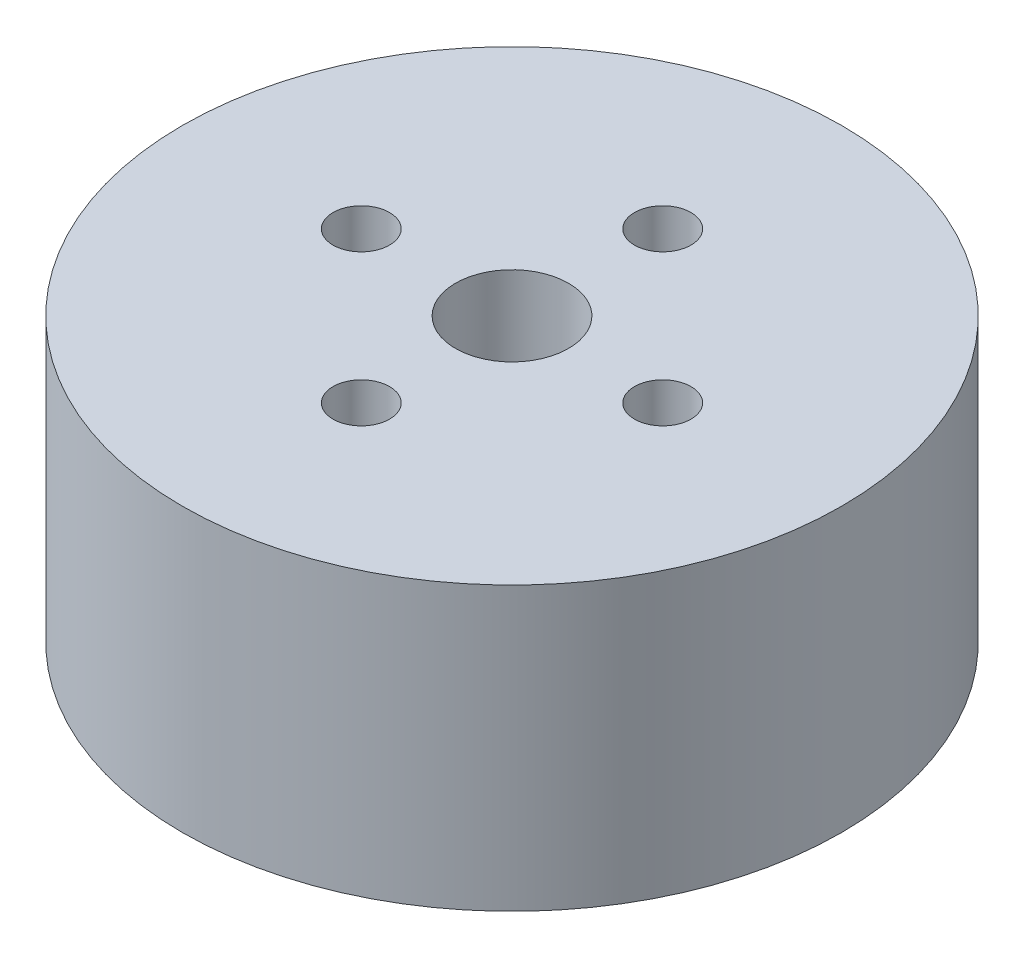
from build123d import *

# Parameters (mm, degrees)
SKETCH_1_R          = 17.5
EXTRUDE_1_DEPTH     = 15
SKETCH_2_R          = 3
CUT_EXTRUDE_1_DEPTH = 16
SKETCH_3_R          = 1.5
CUT_EXTRUDE_2_DEPTH = 5
SKETCH_4_R          = 1.5
CUT_EXTRUDE_3_DEPTH = 5


with BuildPart() as part:
    # 草图1 → 凸台-拉伸1 (new body)
    with BuildSketch(Plane(origin=(0, 0, 0), x_dir=(1, 0, 0), z_dir=(0, 1, 0))):
        Circle(SKETCH_1_R)
    extrude(amount=EXTRUDE_1_DEPTH)

    # 草图2 → 切除-拉伸1 (cut, through all)
    with BuildSketch(Plane(origin=(0, 0, 0), x_dir=(-1, 0, 0), z_dir=(0, -1, 0))):
        Circle(SKETCH_2_R)
    extrude(amount=-CUT_EXTRUDE_1_DEPTH, mode=Mode.SUBTRACT)

    # 草图3 → 切除-拉伸2 (cut)
    with BuildSketch(Plane(origin=(0, 15, 0), x_dir=(1, 0, 0), z_dir=(0, 1, 0))):
        with Locations((0, 8)):
            Circle(SKETCH_3_R)
        with Locations((8, 0)):
            Circle(SKETCH_3_R)
        with Locations((0, -8)):
            Circle(SKETCH_3_R)
        with Locations((-8, 0)):
            Circle(SKETCH_3_R)
    extrude(amount=-CUT_EXTRUDE_2_DEPTH, mode=Mode.SUBTRACT)

    # 草图4 → 切除-拉伸3 (cut)
    with BuildSketch(Plane.XZ):
        with Locations((0, 9.5)):
            Circle(SKETCH_4_R)
        with Locations((9.5, 0)):
            Circle(SKETCH_4_R)
        with Locations((0, -9.5)):
            Circle(SKETCH_4_R)
        with Locations((-9.5, 0)):
            Circle(SKETCH_4_R)
    extrude(amount=-CUT_EXTRUDE_3_DEPTH, mode=Mode.SUBTRACT)


solid = part.part
